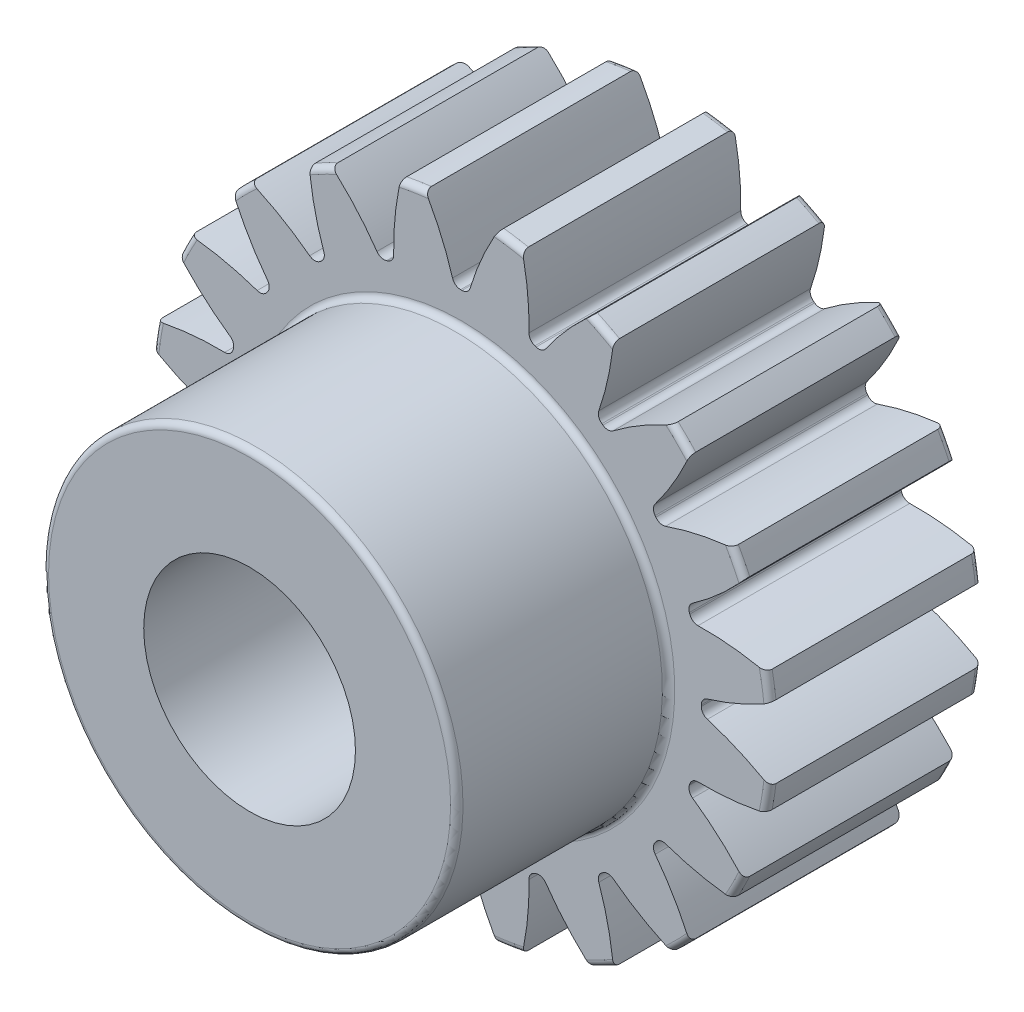
from build123d import *

# Parameters (mm, degrees)
FILLET2_R          = 0.2794
CUT_EXTRUDE2_DEPTH = 10.525
CIRPATTERN1_COUNT  = 20


with BuildPart() as part:
    # Sketch4 → Revolve1 (revolve)
    with BuildSketch(Plane(origin=(0, 0, 0), x_dir=(0, 0, -1), z_dir=(1, 0, 0))):
        Polygon((-19.05, 4.7625), (-19.05, 9.3218), (-9.525, 9.3218), (-9.525, 13.97), (0, 13.97), (0, 4.7625), align=None)
    revolve(axis=Axis((0, 0, 9.525), (0, 0, 1)))

    # Fillet2
    fillet2_edges = [part.edges().sort_by_distance(p)[0] for p in [
        (0, -13.97, 0),
        (0, -13.97, 9.525),
        (0, -9.3218, 9.525),
        (0, -9.3218, 19.05),
    ]]
    fillet(fillet2_edges, radius=FILLET2_R)

    # Sketch7 → Cut-Extrude2 (cut, through all)
    with BuildSketch(Plane.XY.offset(9.525)):
        with BuildLine():
            ThreePointArc((-0.029449487, 10.79495983), (0, 10.795), (0.029449487, 10.79495983))
            ThreePointArc((0.029449487, 10.79495983), (0.257238629, 10.869772623), (0.395246272, 11.06583062))
            ThreePointArc((0.395246272, 11.06583062), (0.92781573, 12.507614405), (1.630655191, 13.874504087))
            ThreePointArc((1.630655191, 13.874504087), (0, 13.97), (-1.630655191, 13.874504087))
            ThreePointArc((-1.630655191, 13.874504087), (-0.92781573, 12.507614405), (-0.395246272, 11.06583062))
            ThreePointArc((-0.395246272, 11.06583062), (-0.257238629, 10.869772623), (-0.029449487, 10.79495983))
        make_face()
    cut_extrude2 = extrude(amount=-CUT_EXTRUDE2_DEPTH, mode=Mode.SUBTRACT)

    # CirPattern1: Cut-Extrude2 ×20 about axis
    cirpattern1_axis = Axis((0, 0, 0), (0, 0, 1))
    for i in range(1, CIRPATTERN1_COUNT):
        add(cut_extrude2.rotate(cirpattern1_axis, i * 360 / CIRPATTERN1_COUNT), mode=Mode.SUBTRACT)


solid = part.part
